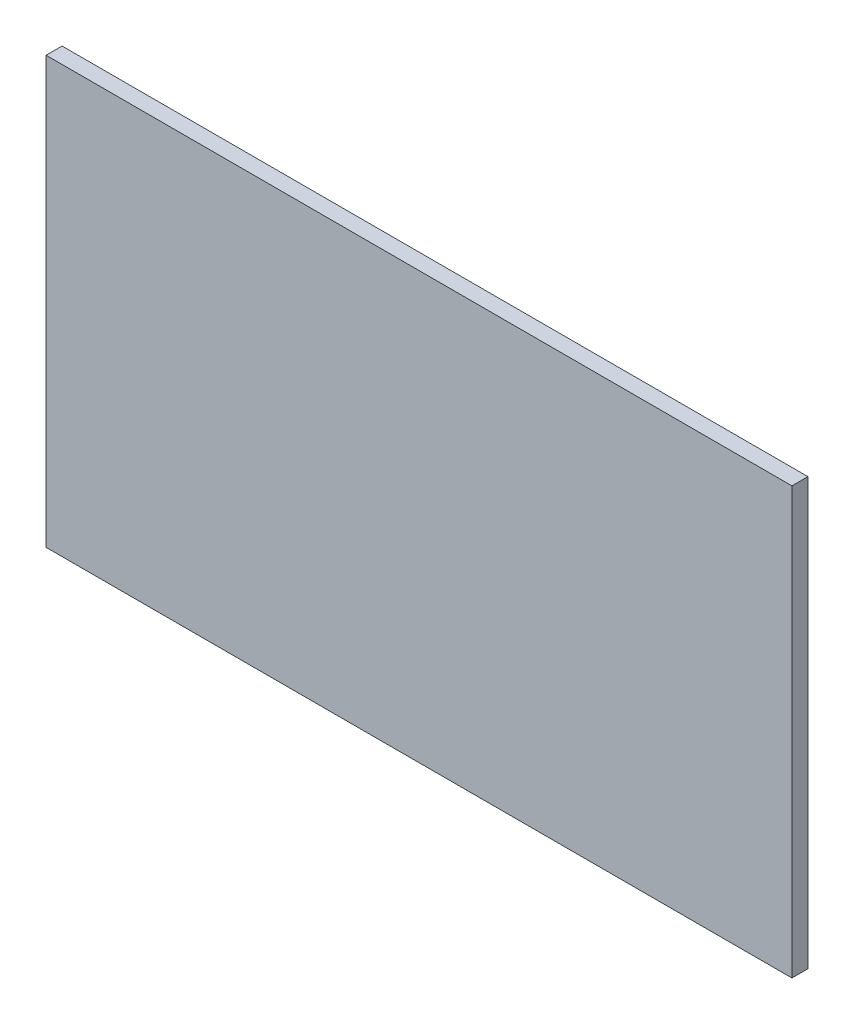
from build123d import *

# Parameters (mm, degrees)
SKETCH2_W           = 140
SKETCH2_H           = 80
BOSS_EXTRUDE1_DEPTH = 3


with BuildPart() as part:
    # Sketch2 → Boss-Extrude1 (new body)
    with BuildSketch(Plane.XY):
        with Locations((70, -40)):
            Rectangle(SKETCH2_W, SKETCH2_H)
    extrude(amount=BOSS_EXTRUDE1_DEPTH)


solid = part.part
